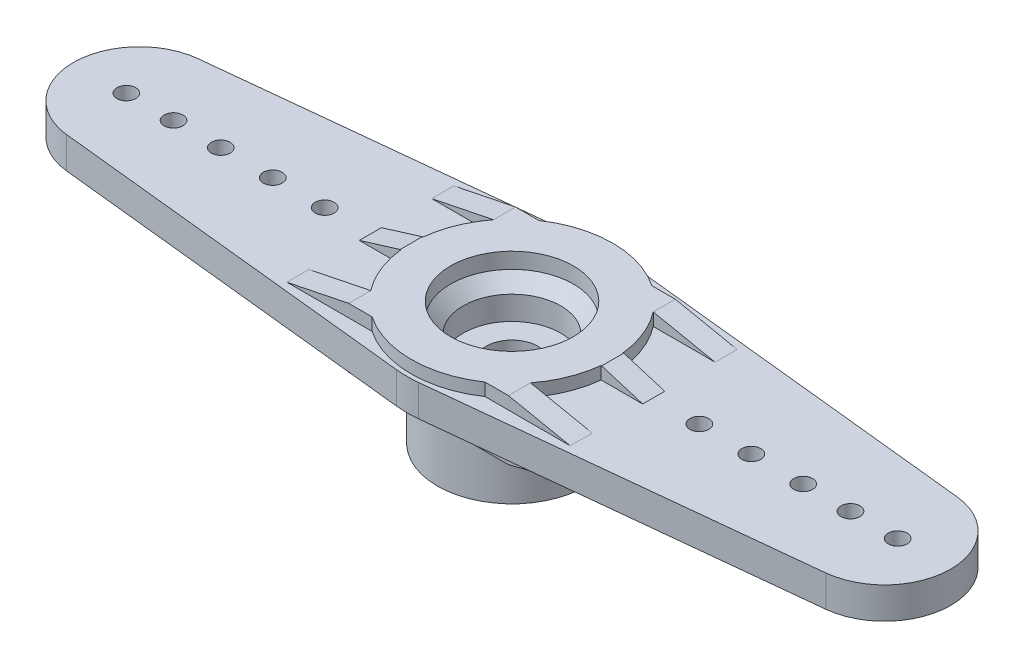
from build123d import *

# Parameters (mm, degrees)
BOSS_EXTRU_1_START           = -2
ESQUISSE3_R                  = 0.6
BOSS_EXTRU_1_DEPTH           = 2
BOSS_EXTRU_2_DEPTH           = 0.8
ENL_V_MAT_EXTRU_6_DEPTH      = 3.77
ENL_V_MAT_EXTRU_7_DEPTH      = 3.77
ENL_V_MAT_EXTRU_8_DEPTH      = 1
ESQUISSE4_R                  = 3.1
ENL_V_MAT_EXTRU_1_DEPTH      = 3.3
ESQUISSE15_W                 = 18
ESQUISSE15_H                 = 1.4
BOSS_EXTRU_3_DEPTH           = 1
ENL_V_MAT_EXTRU_9_DEPTH      = 7.67
ENL_V_MAT_EXTRU_9_DEPTH_BACK = 7.67
ESQUISSE6_R                  = 1.65
ENL_V_MAT_EXTRU_3_DEPTH      = 8.8
ESQUISSE8_R                  = 2.68
ENL_V_MAT_EXTRU_4_DEPTH      = 4.5
ENL_V_MAT_EXTRU_5_DEPTH      = 4.5
R_P_TITION_CIRCULAIRE1_COUNT = 25


with BuildPart() as part:
    # Esquisse2 → Révolution1 (revolve)
    with BuildSketch(Plane.XY):
        Polygon((0, -3.5), (-4.735, -3.5), (-4.735, 1.5), (-6.4, 1.5), (-6.4, 4.3), (0, 4.3), align=None)
    revolve(axis=Axis((0, 3.929571688, 0), (0, -1, 0)))

    # Esquisse3 → Boss.-Extru.1 (add)
    with BuildSketch(Plane(origin=(0, 3.5, 0), x_dir=(1, 0, 0), z_dir=(0, 1, 0)).offset(BOSS_EXTRU_1_START)):
        with BuildLine():
            Line((-24.108276299, 4.177070012), (-0.696024504, 6.633584995))
            ThreePointArc((-0.696024504, 6.633584995), (0, 6.67), (0.696024504, 6.633584995))
            Line((0.696024504, 6.633584995), (24.108276299, 4.177070012))
            ThreePointArc((24.108276299, 4.177070012), (27.87, 0), (24.108276299, -4.177070012))
            Line((24.108276299, -4.177070012), (0.696024504, -6.633584995))
            ThreePointArc((0.696024504, -6.633584995), (0, -6.67), (-0.696024504, -6.633584995))
            Line((-0.696024504, -6.633584995), (-24.108276299, -4.177070012))
            ThreePointArc((-24.108276299, -4.177070012), (-27.87, 0), (-24.108276299, 4.177070012))
        make_face()
        with Locations((-21.5, 0)):
            Circle(ESQUISSE3_R, mode=Mode.SUBTRACT)
        with Locations((-18.5, 0)):
            Circle(ESQUISSE3_R, mode=Mode.SUBTRACT)
        with Locations((-15.2, 0)):
            Circle(ESQUISSE3_R, mode=Mode.SUBTRACT)
        with Locations((15.2, 0)):
            Circle(ESQUISSE3_R, mode=Mode.SUBTRACT)
        with Locations((18.5, 0)):
            Circle(ESQUISSE3_R, mode=Mode.SUBTRACT)
        with Locations((21.5, 0)):
            Circle(ESQUISSE3_R, mode=Mode.SUBTRACT)
        with Locations((-24.5, 0)):
            Circle(ESQUISSE3_R, mode=Mode.SUBTRACT)
        with Locations((-11.9, 0)):
            Circle(ESQUISSE3_R, mode=Mode.SUBTRACT)
        with Locations((11.9, 0)):
            Circle(ESQUISSE3_R, mode=Mode.SUBTRACT)
        with Locations((24.5, 0)):
            Circle(ESQUISSE3_R, mode=Mode.SUBTRACT)
    extrude(amount=BOSS_EXTRU_1_DEPTH)

    # Esquisse10 → Boss.-Extru.2 (add)
    with BuildSketch(Plane(origin=(0, 4.3, 0), x_dir=(1, 0, 0), z_dir=(0, 1, 0))):
        with BuildLine():
            Line((-9, 5.3), (-3.587478223, 5.3))
            ThreePointArc((-3.587478223, 5.3), (-4.387166725, 4.659696141), (-5.074445783, 3.9))
            Line((-5.074445783, 3.9), (-9, 3.9))
            Line((-9, 3.9), (-9, 5.3))
        make_face()
        with BuildLine():
            Line((-9, 0.7), (-6.361603571, 0.7))
            ThreePointArc((-6.361603571, 0.7), (-6.4, 0), (-6.361603571, -0.7))
            Line((-6.361603571, -0.7), (-9, -0.7))
            Line((-9, -0.7), (-9, 0.7))
        make_face()
        with BuildLine():
            Line((-9, -3.9), (-5.074445783, -3.9))
            ThreePointArc((-5.074445783, -3.9), (-4.387166725, -4.659696141), (-3.587478223, -5.3))
            Line((-3.587478223, -5.3), (-9, -5.3))
            Line((-9, -5.3), (-9, -3.9))
        make_face()
        with BuildLine():
            Line((9, -5.3), (3.587478223, -5.3))
            ThreePointArc((3.587478223, -5.3), (4.387166725, -4.659696141), (5.074445783, -3.9))
            Line((5.074445783, -3.9), (9, -3.9))
            Line((9, -3.9), (9, -5.3))
        make_face()
        with BuildLine():
            Line((9, -0.7), (6.361603571, -0.7))
            ThreePointArc((6.361603571, -0.7), (6.4, 0), (6.361603571, 0.7))
            Line((6.361603571, 0.7), (9, 0.7))
            Line((9, 0.7), (9, -0.7))
        make_face()
        with BuildLine():
            Line((9, 3.9), (5.074445783, 3.9))
            ThreePointArc((5.074445783, 3.9), (4.387166725, 4.659696141), (3.587478223, 5.3))
            Line((3.587478223, 5.3), (9, 5.3))
            Line((9, 5.3), (9, 3.9))
        make_face()
    extrude(amount=-BOSS_EXTRU_2_DEPTH)

    # Esquisse11 → Enlèv. mat.-Extru.6 (cut, through all)
    with BuildSketch(Plane.XY.offset(-3.9)):
        Polygon((-5.074445783, 4.3), (-9, 3.5), (-9, 4.3), align=None)
        Polygon((9, 4.3), (5.074445783, 4.3), (9, 3.5), align=None)
    extrude(amount=-ENL_V_MAT_EXTRU_6_DEPTH, mode=Mode.SUBTRACT)

    # Esquisse12 → Enlèv. mat.-Extru.7 (cut, through all)
    with BuildSketch(Plane(origin=(0, 0, 3.9), x_dir=(-1, 0, 0), z_dir=(0, 0, -1))):
        Polygon((-5.074445783, 4.3), (-9, 4.3), (-9, 3.5), align=None)
        Polygon((5.074445783, 4.3), (9, 3.5), (9, 4.3), align=None)
    extrude(amount=-ENL_V_MAT_EXTRU_7_DEPTH, mode=Mode.SUBTRACT)

    # Esquisse13 → Enlèv. mat.-Extru.8 (cut, symmetric)
    with BuildSketch(Plane.XY):
        Polygon((-6.4, 4.3), (-9, 3.5), (-9, 4.3), align=None)
        Polygon((6.4, 4.3), (9, 4.3), (9, 3.5), align=None)
    extrude(amount=ENL_V_MAT_EXTRU_8_DEPTH, both=True, mode=Mode.SUBTRACT)

    # Esquisse4 → Enlèv. mat.-Extru.1 (cut)
    with BuildSketch(Plane(origin=(0, 4.3, 0), x_dir=(1, 0, 0), z_dir=(0, 1, 0))):
        Circle(ESQUISSE4_R)
    extrude(amount=-ENL_V_MAT_EXTRU_1_DEPTH, mode=Mode.SUBTRACT)

    # Esquisse14 → Enlèvement de matière-Révolution1 (revolve, cut)
    with BuildSketch(Plane.XY):
        Polygon((-3.9, 4.3), (-3.9, 3.3), (-3.1, 2.5), (0, 2.5), (0, 4.3), align=None)
    revolve(axis=Axis((0, 4.3, 0), (0, -1, 0)), mode=Mode.SUBTRACT)

    # Esquisse15 → Boss.-Extru.3 (add)
    with BuildSketch(Plane.XZ.offset(-1.5)):
        with Locations((0, 4.6)):
            Rectangle(ESQUISSE15_W, ESQUISSE15_H)
        with Locations((0, -4.6)):
            Rectangle(ESQUISSE15_W, ESQUISSE15_H)
    extrude(amount=BOSS_EXTRU_3_DEPTH)

    # Esquisse16 → Enlèv. mat.-Extru.9 (cut, two sides)
    with BuildSketch(Plane.XY) as enl_v_mat_extru_9_sk:
        Polygon((-9, 1.5), (-5.074445783, 0.5), (-9, 0.5), align=None)
        Polygon((9, 0.5), (5.074445783, 0.5), (9, 1.5), align=None)
    extrude(amount=ENL_V_MAT_EXTRU_9_DEPTH, mode=Mode.SUBTRACT)
    extrude(enl_v_mat_extru_9_sk.sketch, amount=-ENL_V_MAT_EXTRU_9_DEPTH_BACK, mode=Mode.SUBTRACT)

    # Esquisse6 → Enlèv. mat.-Extru.3 (cut, through all)
    with BuildSketch(Plane.XZ.offset(3.5)):
        Circle(ESQUISSE6_R)
    extrude(amount=-ENL_V_MAT_EXTRU_3_DEPTH, mode=Mode.SUBTRACT)

    # Esquisse8 → Enlèv. mat.-Extru.4 (cut, through all)
    with BuildSketch(Plane(origin=(0, 0, 0), x_dir=(1, 0, 0), z_dir=(0, 1, 0))):
        Circle(ESQUISSE8_R)
    extrude(amount=-ENL_V_MAT_EXTRU_4_DEPTH, mode=Mode.SUBTRACT)

    # Esquisse9 → Enlèv. mat.-Extru.5 (cut, through all)
    with BuildSketch(Plane(origin=(0, 0, 0), x_dir=(1, 0, 0), z_dir=(0, 1, 0))):
        with BuildLine():
            Line((0.10528472, -3.048182266), (0.265600366, -2.666806413))
            ThreePointArc((0.265600366, -2.666806413), (0, -2.68), (-0.265600366, -2.666806413))
            Line((-0.265600366, -2.666806413), (-0.10528472, -3.048182266))
            ThreePointArc((-0.10528472, -3.048182266), (0, -3.05), (0.10528472, -3.048182266))
        make_face()
    enl_v_mat_extru_5 = extrude(amount=-ENL_V_MAT_EXTRU_5_DEPTH, mode=Mode.SUBTRACT)

    # Répétition circulaire1: Enlèv. mat.-Extru.5 ×25 about axis
    r_p_tition_circulaire1_axis = Axis((0, 0, 0), (0, 1, 0))
    for i in range(1, R_P_TITION_CIRCULAIRE1_COUNT):
        add(enl_v_mat_extru_5.rotate(r_p_tition_circulaire1_axis, i * 360 / R_P_TITION_CIRCULAIRE1_COUNT), mode=Mode.SUBTRACT)


solid = part.part
